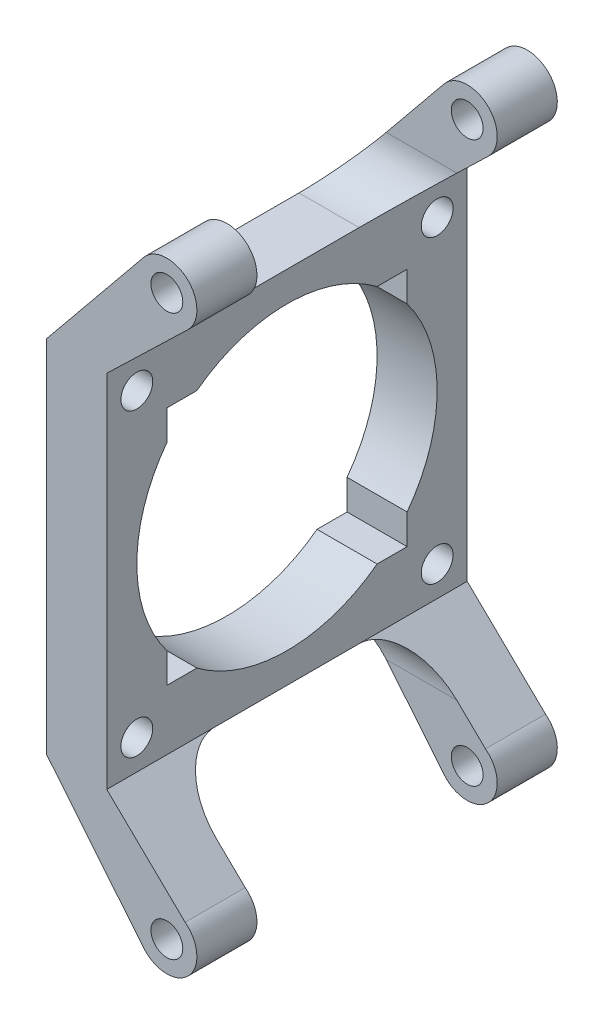
from build123d import *

# Parameters (mm, degrees)
SKETCH_1_W          = 10
SKETCH_1_H          = 40
SKETCH_1_H_2        = 10
SKETCH_1_R          = 5
SKETCH_1_R_2        = 2.65
EXTRUDE_1_DEPTH     = 10
SKETCH_1_5_W        = 10
SKETCH_1_5_H        = 10
EXTRUDE_2_DEPTH     = 50
EXTRUDE_START       = 50
SKETCH_1_6_R        = 5
SKETCH_1_6_R_2      = 2.65
SKETCH_1_6_W        = 10
SKETCH_1_6_H        = 10
SKETCH_1_6_H_2      = 40
EXTRUDE_3_DEPTH     = 10
SKETCH_2_R          = 25
CUT_EXTRUDE_1_DEPTH = 118.763491796
SKETCH_3_R          = 2.65
CUT_EXTRUDE_2_DEPTH = 117.052746628
FILLET_1_R          = 8


with BuildPart() as part:
    # 草图1 → 凸台-拉伸1 (new body)
    with BuildSketch(Plane.XY):
        with Locations((-15, -46.6)):
            Rectangle(SKETCH_1_W, SKETCH_1_H)
        with Locations((-15, -21.6)):
            Rectangle(SKETCH_1_W, SKETCH_1_H_2)
        with BuildLine():
            Line((-3.873829785, 3.161240705), (-20, -16.6))
            Line((-20, -16.6), (-10, -16.6))
            Line((-10, -16.6), (3.472226939, -3.597727072))
            ThreePointArc((3.472226939, -3.597727072), (-3.38544422, -3.679506412), (-3.873829785, 3.161240705))
        make_face()
        Circle(SKETCH_1_R)
        Circle(SKETCH_1_R_2, mode=Mode.SUBTRACT)
        with Locations((-15, -71.6)):
            Rectangle(SKETCH_1_W, SKETCH_1_H_2)
        with BuildLine():
            Line((-10, -76.6), (-20, -76.6))
            Line((-20, -76.6), (-3.873829785, -96.361240705))
            ThreePointArc((-3.873829785, -96.361240705), (-3.587719738, -89.717433837), (3.044640112, -89.233872595))
            Line((3.044640112, -89.233872595), (-10, -76.6))
        make_face()
        with Locations((0, -93.2)):
            Circle(SKETCH_1_R)
        with Locations((0, -93.2)):
            Circle(SKETCH_1_R_2, mode=Mode.SUBTRACT)
    extrude(amount=EXTRUDE_1_DEPTH)

    # 草图1<5> → 凸台-拉伸2 (add)
    with BuildSketch(Plane.XY):
        with Locations((-15, -21.6)):
            Rectangle(SKETCH_1_5_W, SKETCH_1_5_H)
        with Locations((-15, -71.6)):
            Rectangle(SKETCH_1_5_W, SKETCH_1_5_H)
    extrude(amount=EXTRUDE_2_DEPTH)

    # 草图1<6> → 凸台-拉伸3 (add)
    with BuildSketch(Plane.XY.offset(EXTRUDE_START)):
        Circle(SKETCH_1_6_R)
        Circle(SKETCH_1_6_R_2, mode=Mode.SUBTRACT)
        with BuildLine():
            Line((-3.873829785, 3.161240705), (-20, -16.6))
            Line((-20, -16.6), (-10, -16.6))
            Line((-10, -16.6), (3.472226939, -3.597727072))
            ThreePointArc((3.472226939, -3.597727072), (-3.38544422, -3.679506412), (-3.873829785, 3.161240705))
        make_face()
        with Locations((-15, -21.6)):
            Rectangle(SKETCH_1_6_W, SKETCH_1_6_H)
        with Locations((-15, -46.6)):
            Rectangle(SKETCH_1_6_W, SKETCH_1_6_H_2)
        with Locations((-15, -71.6)):
            Rectangle(SKETCH_1_6_W, SKETCH_1_6_H)
        with Locations((0, -93.2)):
            Circle(SKETCH_1_6_R)
        with Locations((0, -93.2)):
            Circle(SKETCH_1_6_R_2, mode=Mode.SUBTRACT)
        with BuildLine():
            Line((-10, -76.6), (-20, -76.6))
            Line((-20, -76.6), (-3.873829785, -96.361240705))
            ThreePointArc((-3.873829785, -96.361240705), (-3.587719738, -89.717433837), (3.044640112, -89.233872595))
            Line((3.044640112, -89.233872595), (-10, -76.6))
        make_face()
    extrude(amount=EXTRUDE_3_DEPTH)

    # 草图2 → 切除-拉伸1 (cut, through all)
    with BuildSketch(Plane.ZY.offset(20)):
        with Locations((30, -46.6)):
            Circle(SKETCH_2_R)
    extrude(amount=-CUT_EXTRUDE_1_DEPTH, mode=Mode.SUBTRACT)

    # 草图3 → 切除-拉伸2 (cut, through all)
    with BuildSketch(Plane(origin=(-10, 0, 0), x_dir=(0, 0, -1), z_dir=(1, 0, 0))):
        with Locations(Location((-55, -21.6, 0), (0, 0, 90))):
            Circle(SKETCH_3_R)
        with Locations(Location((-5, -21.6, 0), (0, 0, 90))):
            Circle(SKETCH_3_R)
        with Locations(Location((-55, -71.6, 0), (0, 0, 90))):
            Circle(SKETCH_3_R)
        with Locations(Location((-5, -71.6, 0), (0, 0, 90))):
            Circle(SKETCH_3_R)
    extrude(amount=-CUT_EXTRUDE_2_DEPTH, mode=Mode.SUBTRACT)

    # 圆角1
    fillet_1_edges = [part.edges().sort_by_distance(p)[0] for p in [
        (-15, -16.6, 10),
        (-15, -16.6, 50),
        (-15, -76.6, 10),
        (-15, -76.6, 50),
    ]]
    fillet(fillet_1_edges, radius=FILLET_1_R)


solid = part.part
